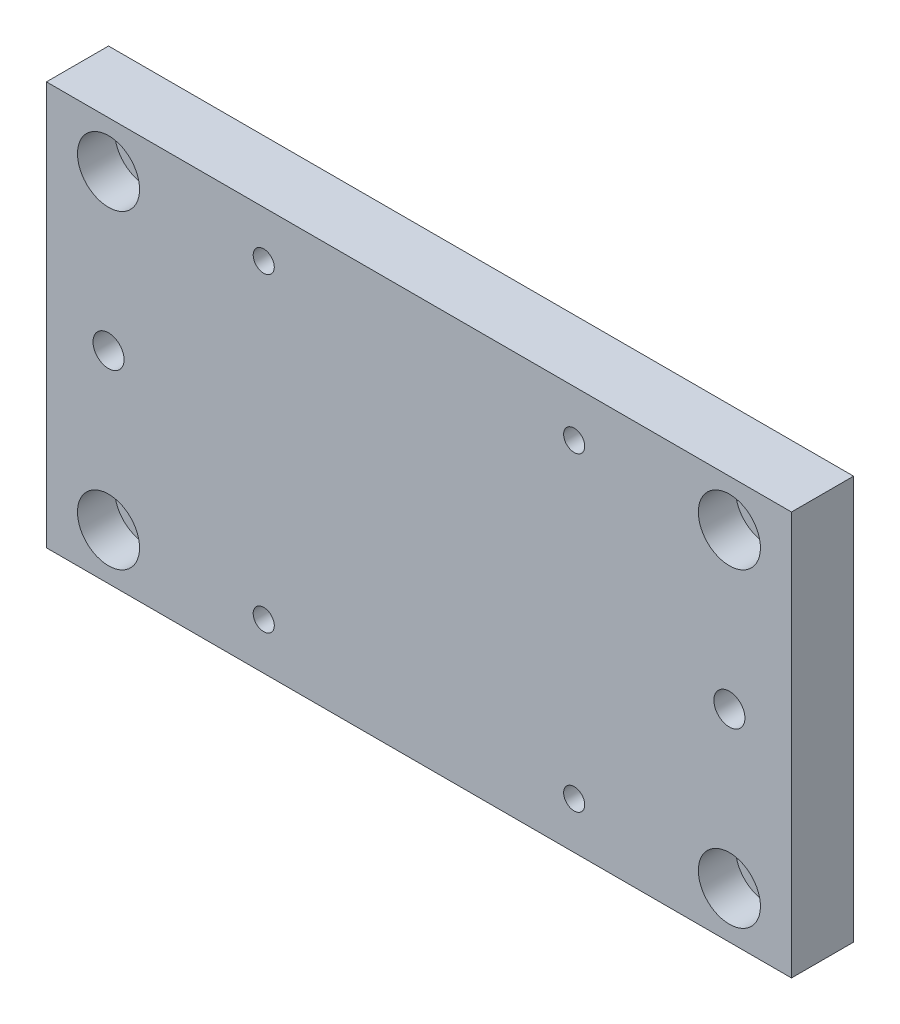
from build123d import *

# Parameters (mm, degrees)
SKETCH1_W           = 120
SKETCH1_H           = 65
SKETCH1_R           = 1.7
SKETCH1_R_2         = 3.05
SKETCH1_R_3         = 2.5
BOSS_EXTRUDE1_DEPTH = 10
SKETCH2_R           = 5
CUT_EXTRUDE1_DEPTH  = 6


with BuildPart() as part:
    # Sketch1 → Boss-Extrude1 (new body)
    with BuildSketch(Plane.XY):
        with Locations((60, 32.5)):
            Rectangle(SKETCH1_W, SKETCH1_H)
        with Locations((85, 7.5)):
            Circle(SKETCH1_R, mode=Mode.SUBTRACT)
        with Locations((85, 57.5)):
            Circle(SKETCH1_R, mode=Mode.SUBTRACT)
        with Locations((35, 7.5)):
            Circle(SKETCH1_R, mode=Mode.SUBTRACT)
        with Locations((35, 57.5)):
            Circle(SKETCH1_R, mode=Mode.SUBTRACT)
        with Locations((110, 7.5)):
            Circle(SKETCH1_R_2, mode=Mode.SUBTRACT)
        with Locations((110, 57.5)):
            Circle(SKETCH1_R_2, mode=Mode.SUBTRACT)
        with Locations((10, 7.5)):
            Circle(SKETCH1_R_2, mode=Mode.SUBTRACT)
        with Locations((10, 57.5)):
            Circle(SKETCH1_R_2, mode=Mode.SUBTRACT)
        with Locations((110, 32.5)):
            Circle(SKETCH1_R_3, mode=Mode.SUBTRACT)
        with Locations((10, 32.5)):
            Circle(SKETCH1_R_3, mode=Mode.SUBTRACT)
    extrude(amount=BOSS_EXTRUDE1_DEPTH)

    # Sketch2 → Cut-Extrude1 (cut)
    with BuildSketch(Plane.XY.offset(10)):
        with Locations((110, 7.5)):
            Circle(SKETCH2_R)
        with Locations((110, 57.5)):
            Circle(SKETCH2_R)
        with Locations((10, 57.5)):
            Circle(SKETCH2_R)
        with Locations((10, 7.5)):
            Circle(SKETCH2_R)
    extrude(amount=-CUT_EXTRUDE1_DEPTH, mode=Mode.SUBTRACT)


solid = part.part
